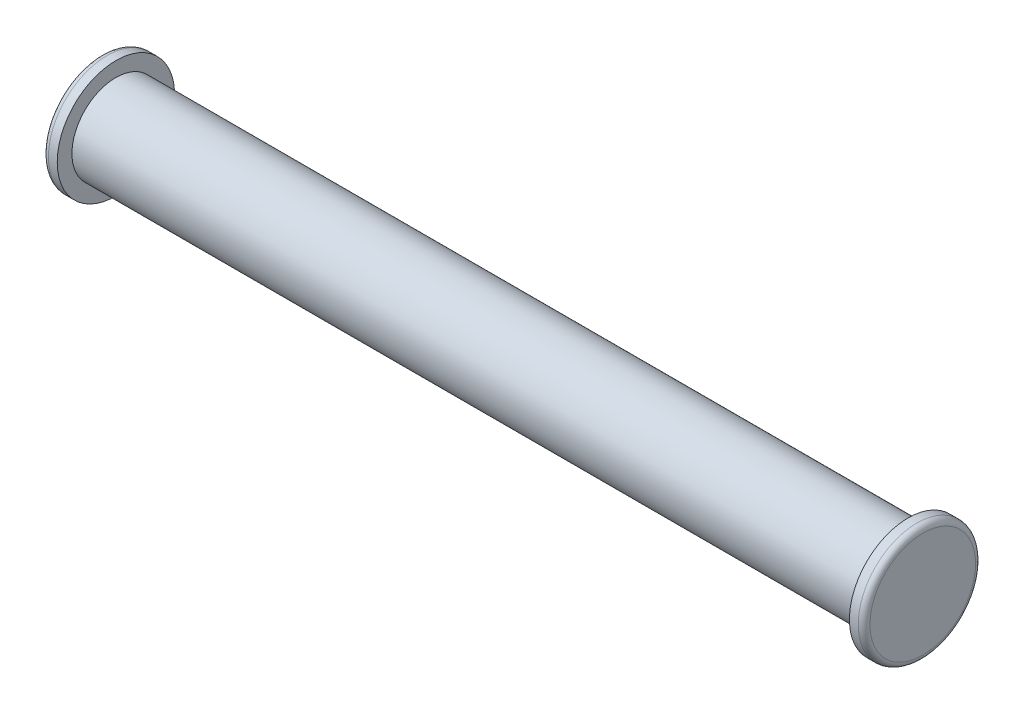
from build123d import *

# Parameters (mm, degrees)
SKETCH1_R           = 1.5
BOSS_EXTRUDE1_DEPTH = 13.5
SKETCH2_R           = 2
BOSS_EXTRUDE2_DEPTH = 0.5
SKETCH3_R           = 2
BOSS_EXTRUDE3_DEPTH = 0.5
FILLET1_R           = 0.2


with BuildPart() as part:
    # Sketch1 → Boss-Extrude1 (new body, symmetric)
    with BuildSketch(Plane(origin=(0, 0, 0), x_dir=(0, 0, -1), z_dir=(1, 0, 0))):
        Circle(SKETCH1_R)
    extrude(amount=BOSS_EXTRUDE1_DEPTH, both=True)

    # Sketch2 → Boss-Extrude2 (add)
    with BuildSketch(Plane(origin=(13.5, 0, 0), x_dir=(0, 0, -1), z_dir=(1, 0, 0))):
        Circle(SKETCH2_R)
    extrude(amount=BOSS_EXTRUDE2_DEPTH)

    # Sketch3 → Boss-Extrude3 (add)
    with BuildSketch(Plane.ZY.offset(13.5)):
        Circle(SKETCH3_R)
    extrude(amount=BOSS_EXTRUDE3_DEPTH)

    # Fillet1
    fillet1_edges = [part.edges().sort_by_distance(p)[0] for p in [
        (-14, 0, -2),
        (14, 0, 2),
    ]]
    fillet(fillet1_edges, radius=FILLET1_R)


solid = part.part
